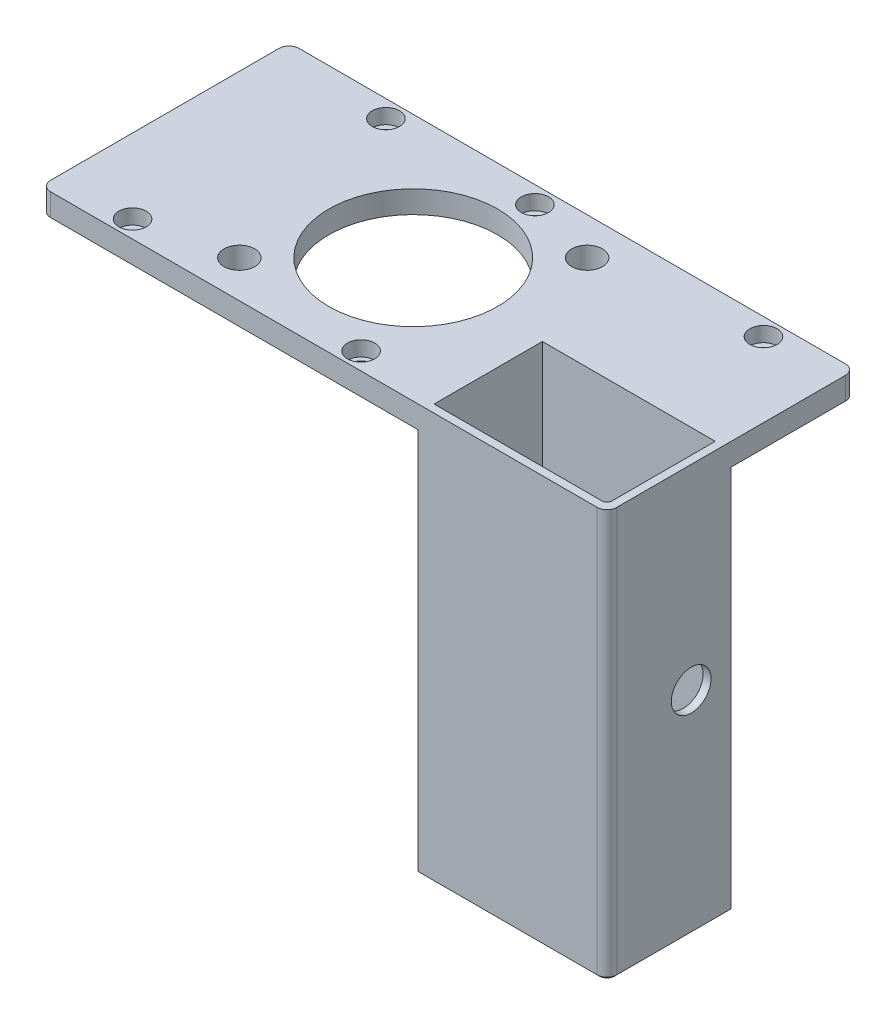
from build123d import *

# Parameters (mm, degrees)
CROQUIS1_R              = 1.6
CROQUIS1_R_2            = 1.528989044
CROQUIS1_R_3            = 1.814858399
SALIENTE_EXTRUIR1_DEPTH = 4.5
CROQUIS2_R              = 3.1
CROQUIS2_R_2            = 17
CORTAR_EXTRUIR1_DEPTH   = 5.5
CROQUIS3_R              = 2.75
CORTAR_EXTRUIR2_DEPTH   = 3
CROQUIS4_W              = 38
CROQUIS4_H              = 25
CROQUIS4_W_2            = 34.8
CROQUIS4_H_2            = 21.8
SALIENTE_EXTRUIR2_DEPTH = 82
CROQUIS5_R              = 1.6
CORTAR_EXTRUIR3_DEPTH   = 82
CORTAR_EXTRUIR4_REACH   = 116
CROQUIS6_R              = 4
REDONDEO1_R             = 2
REDONDEO2_R             = 1
CHAFL_N1_SIZE           = 0.5


with BuildPart() as part:
    # Croquis1 → Saliente-Extruir1 (new body)
    with BuildSketch(Plane(origin=(0, 0, 0), x_dir=(1, 0, 0), z_dir=(0, 1, 0))):
        Polygon((76, 25), (76, 0), (38, 0), (38, -25), (-38, -25), (-38, 0), (-38, 25), align=None)
        with Locations((-15, 21.5)):
            Circle(CROQUIS1_R, mode=Mode.SUBTRACT)
        with Locations((15, 21.5)):
            Circle(CROQUIS1_R, mode=Mode.SUBTRACT)
        with Locations((-23, -21.5)):
            Circle(CROQUIS1_R_2, mode=Mode.SUBTRACT)
        with Locations((23, -21.5)):
            Circle(CROQUIS1_R_3, mode=Mode.SUBTRACT)
        with Locations((61, 21.5)):
            Circle(CROQUIS1_R, mode=Mode.SUBTRACT)
    extrude(amount=SALIENTE_EXTRUIR1_DEPTH)

    # Croquis2 → Cortar-Extruir1 (cut, through all)
    with BuildSketch(Plane(origin=(0, 4.5, 0), x_dir=(1, 0, 0), z_dir=(0, 1, 0))):
        with Locations((29.5, 17.5)):
            Circle(CROQUIS2_R)
        with Locations((-5.5, -17.5)):
            Circle(CROQUIS2_R)
        with Locations((12, 0)):
            Circle(CROQUIS2_R_2)
    extrude(amount=-CORTAR_EXTRUIR1_DEPTH, mode=Mode.SUBTRACT)

    # Croquis3 → Cortar-Extruir2 (cut)
    with BuildSketch(Plane(origin=(0, 4.5, 0), x_dir=(1, 0, 0), z_dir=(0, 1, 0))):
        with Locations((-15, 21.5)):
            Circle(CROQUIS3_R)
        with Locations((15, 21.5)):
            Circle(CROQUIS3_R)
        with Locations((61, 21.5)):
            Circle(CROQUIS3_R)
        with Locations((23, -21.5)):
            Circle(CROQUIS3_R)
        with Locations((-23, -21.5)):
            Circle(CROQUIS3_R)
    extrude(amount=-CORTAR_EXTRUIR2_DEPTH, mode=Mode.SUBTRACT)

    # Croquis4 → Saliente-Extruir2 (add)
    with BuildSketch(Plane(origin=(0, 4.5, 0), x_dir=(1, 0, 0), z_dir=(0, 1, 0))):
        with Locations((57, -12.5)):
            Rectangle(CROQUIS4_W, CROQUIS4_H)
        with Locations((57, -12.5)):
            Rectangle(CROQUIS4_W_2, CROQUIS4_H_2, mode=Mode.SUBTRACT)
    extrude(amount=-SALIENTE_EXTRUIR2_DEPTH)

    # Croquis5 → Cortar-Extruir3 (cut)
    with BuildSketch(Plane.XY.offset(1.6)):
        with Locations((53.5, -73.5)):
            Circle(CROQUIS5_R)
    extrude(amount=-CORTAR_EXTRUIR3_DEPTH, mode=Mode.SUBTRACT)

    # Croquis6 → Cortar-Extruir4 (cut, up to next)
    with BuildSketch(Plane(origin=(76, 0, 0), x_dir=(0, 0, -1), z_dir=(1, 0, 0)), mode=Mode.PRIVATE) as cortar_extruir4_sk1:
        with Locations((-8.049586481, -34.845975381)):
            Circle(CROQUIS6_R)
    cortar_extruir4_tool1 = extrude(cortar_extruir4_sk1.sketch, amount=-CORTAR_EXTRUIR4_REACH, mode=Mode.PRIVATE) & part.part
    add(cortar_extruir4_tool1.solids().sort_by_distance((76, -34.845975, 8.049586))[0], mode=Mode.SUBTRACT)

    # Redondeo1
    redondeo1_edges = [part.edges().sort_by_distance(p)[0] for p in [
        (-38, 2.25, 25),
        (-38, 2.25, -25),
        (76, 2.25, -25),
        (76, -36.5, 25),
    ]]
    fillet(redondeo1_edges, radius=REDONDEO1_R)

    # Redondeo2
    redondeo2_edges = [part.edges().sort_by_distance(p)[0] for p in [
        (74.4, -36.5, 23.4),
    ]]
    fillet(redondeo2_edges, radius=REDONDEO2_R)

    # Chaflán1
    chafl_n1_edges = [part.edges().sort_by_distance(p)[0] for p in [
        (76, -77.5, 11.5),
        (75.414213562, -77.5, 24.414213562),
        (56, -77.5, 25),
    ]]
    chamfer(chafl_n1_edges, length=CHAFL_N1_SIZE)


solid = part.part
